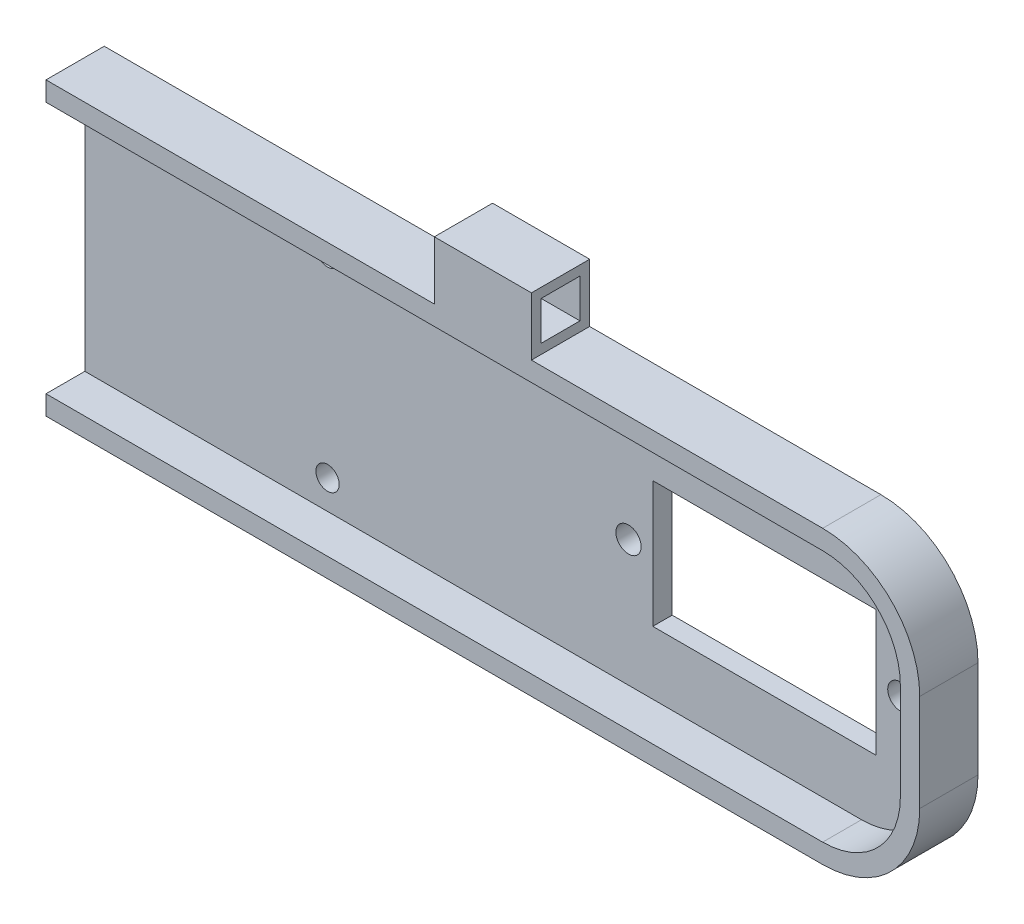
from build123d import *

# Parameters (mm, degrees)
SZKIC1_R                    = 22.5
DODANIE_WYCI_GNI_CIE2_DEPTH = 13
SZKIC2_W                    = 220
SZKIC2_H                    = 30
DODANIE_WYCI_GNI_CIE3_DEPTH = 6
ZAOKR_GLENIE1_R             = 10
SZKIC4_R                    = 20.5
WYTNIJ_WYCI_GNI_CIE3_DEPTH  = 11
WYTNIJ_WYCI_GNI_CIE2_DEPTH  = 4
WYTNIJ_WYCI_GNI_CIE4_REACH  = 173.975
SZKIC8_W                    = 23
SZKIC8_H                    = 13
SZKIC12_R                   = 3.3
DODANIE_WYCI_GNI_CIE4_DEPTH = 3
OTW_R_POD_RUB_M21_D         = 2.6
OTW_R_POD_RUB_M23_D         = 2.6
SZKIC14_R                   = 3.3
DODANIE_WYCI_GNI_CIE5_DEPTH = 5
OTW_R_POD_RUB_M24_D         = 2.6
SZKIC15_W                   = 6
SZKIC15_H                   = 6
SZKIC15_W_2                 = 4
SZKIC15_H_2                 = 4
DODANIE_WYCI_GNI_CIE6_DEPTH = 10
SZYK_LINIOWY1_COUNT         = 2
SZYK_LINIOWY1_PITCH         = 70
OTW_R_POD_RUB_M25_D         = 2.4


with BuildPart() as part:
    # Szkic1 → Dodanie-wyciągnięcie2 (new body)
    with BuildSketch(Plane.XY):
        with Locations(Location((0, 0, 0), (0, 0, 180))):
            Circle(SZKIC1_R)
    extrude(amount=DODANIE_WYCI_GNI_CIE2_DEPTH)

    # Szkic2 → Dodanie-wyciągnięcie3 (add)
    with BuildSketch(Plane.XY):
        with Locations((60, 0)):
            Rectangle(SZKIC2_W, SZKIC2_H)
    extrude(amount=DODANIE_WYCI_GNI_CIE3_DEPTH)

    # Zaokrąglenie1
    zaokr_glenie1_edges = [part.edges().sort_by_distance(p)[0] for p in [
        (170, 15, 3),
        (-50, -15, 3),
        (170, -15, 3),
        (-50, 15, 3),
    ]]
    fillet(zaokr_glenie1_edges, radius=ZAOKR_GLENIE1_R)

    # Szkic4 → Wytnij-wyciągnięcie3 (cut)
    with BuildSketch(Plane.XY.offset(13)):
        Circle(SZKIC4_R)
    extrude(amount=-WYTNIJ_WYCI_GNI_CIE3_DEPTH, mode=Mode.SUBTRACT)

    # Szkic3 → Wytnij-wyciągnięcie2 (cut)
    with BuildSketch(Plane.XY.offset(6)):
        with BuildLine():
            Line((168, -5), (168, 5))
            ThreePointArc((168, 5), (165.656854249, 10.656854249), (160, 13))
            Line((160, 13), (20.766559657, 13))
            ThreePointArc((20.766559657, 13), (24.5, 0), (20.766559657, -13))
            Line((20.766559657, -13), (160, -13))
            ThreePointArc((160, -13), (165.656854249, -10.656854249), (168, -5))
        make_face()
        with BuildLine():
            Line((-48, 5), (-48, -5))
            ThreePointArc((-48, -5), (-45.656854249, -10.656854249), (-40, -13))
            Line((-40, -13), (-20.766559657, -13))
            ThreePointArc((-20.766559657, -13), (-24.5, 0), (-20.766559657, 13))
            Line((-20.766559657, 13), (-40, 13))
            ThreePointArc((-40, 13), (-45.656854249, 10.656854249), (-48, 5))
        make_face()
    extrude(amount=-WYTNIJ_WYCI_GNI_CIE2_DEPTH, mode=Mode.SUBTRACT)

    # Szkic8 → Wytnij-wyciągnięcie4 (cut, up to next)
    with BuildSketch(Plane.XY, mode=Mode.PRIVATE) as wytnij_wyci_gni_cie4_sk1:
        with Locations((150, 0)):
            Rectangle(SZKIC8_W, SZKIC8_H)
    wytnij_wyci_gni_cie4_tool1 = extrude(wytnij_wyci_gni_cie4_sk1.sketch, amount=WYTNIJ_WYCI_GNI_CIE4_REACH, mode=Mode.PRIVATE) & part.part
    add(wytnij_wyci_gni_cie4_tool1.solids().sort_by_distance((150, 0, 0))[0], mode=Mode.SUBTRACT)

    # Szkic12 → Dodanie-wyciągnięcie4 (add)
    with BuildSketch(Plane.XY.offset(2)):
        Circle(SZKIC12_R)
    extrude(amount=DODANIE_WYCI_GNI_CIE4_DEPTH)

    # Otwór pod śrubę M21 (through all)
    with Locations(Plane(origin=(0, 0, 0), x_dir=(1, 0, 0), z_dir=(0, 0, -1))):
        with Locations((0, 0)):
            Hole(OTW_R_POD_RUB_M21_D / 2)

    # Otwór pod śrubę M23 (through all)
    with Locations(Plane(origin=(0, 0, 0), x_dir=(1, 0, 0), z_dir=(0, 0, -1))):
        with Locations((136, 0), (164, 0)):
            Hole(OTW_R_POD_RUB_M23_D / 2)

    # Szkic14 → Dodanie-wyciągnięcie5 (add)
    with BuildSketch(Plane.XY.offset(2)):
        with Locations((-40, 0)):
            Circle(SZKIC14_R)
    extrude(amount=DODANIE_WYCI_GNI_CIE5_DEPTH)

    # Otwór pod śrubę M24 (through all)
    with Locations(Plane(origin=(-40, 0, 0), x_dir=(-1, 0, 0), z_dir=(0, 0, -1))):
        with Locations((0, 0)):
            Hole(OTW_R_POD_RUB_M24_D / 2)

    # Szkic15 → Dodanie-wyciągnięcie6 (add)
    with BuildSketch(Plane(origin=(130, 0, 0), x_dir=(0, 0, -1), z_dir=(1, 0, 0))):
        with Locations((-3, 18)):
            Rectangle(SZKIC15_W, SZKIC15_H)
        with Locations((-3, 18)):
            Rectangle(SZKIC15_W_2, SZKIC15_H_2, mode=Mode.SUBTRACT)
    dodanie_wyci_gni_cie6 = extrude(amount=-DODANIE_WYCI_GNI_CIE6_DEPTH)

    # Szyk liniowy1: Dodanie-wyciągnięcie6 ×2
    with Locations(*[(-i * SZYK_LINIOWY1_PITCH, 0, 0) for i in range(1, SZYK_LINIOWY1_COUNT)]):
        add(dodanie_wyci_gni_cie6)

    # Otwór pod śrubę M25 (through all)
    with Locations(Plane.XY.offset(2)):
        with Locations((55, -10), (105, -10), (105, 10), (55, 10)):
            Hole(OTW_R_POD_RUB_M25_D / 2)

    # Cięcie powierzchnią1
    split(bisect_by=Plane(origin=(80, 0, 0), x_dir=(0, 0, -1), z_dir=(1, 0, 0)), keep=Keep.TOP)


solid = part.part
